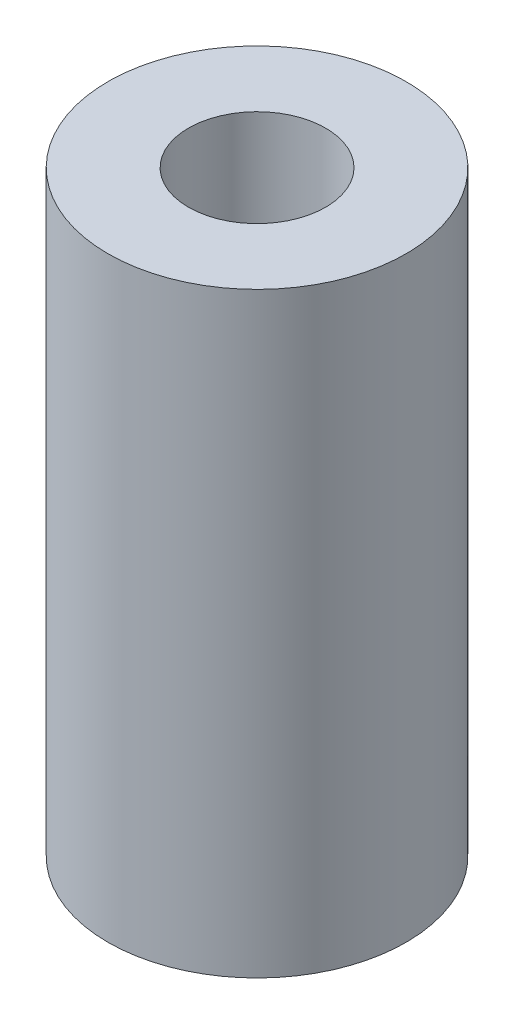
from build123d import *

# Parameters (mm, degrees)
SKETCH1_R           = 2.5
BOSS_EXTRUDE1_DEPTH = 10
SKETCH2_R           = 1.15
CUT_EXTRUDE1_DEPTH  = 8


with BuildPart() as part:
    # Sketch1 → Boss-Extrude1 (new body)
    with BuildSketch(Plane(origin=(0, 0, 0), x_dir=(1, 0, 0), z_dir=(0, 1, 0))):
        Circle(SKETCH1_R)
    extrude(amount=BOSS_EXTRUDE1_DEPTH)

    # Sketch2 → Cut-Extrude1 (cut)
    with BuildSketch(Plane(origin=(0, 10, 0), x_dir=(1, 0, 0), z_dir=(0, 1, 0))):
        Circle(SKETCH2_R)
    extrude(amount=-CUT_EXTRUDE1_DEPTH, mode=Mode.SUBTRACT)


solid = part.part
